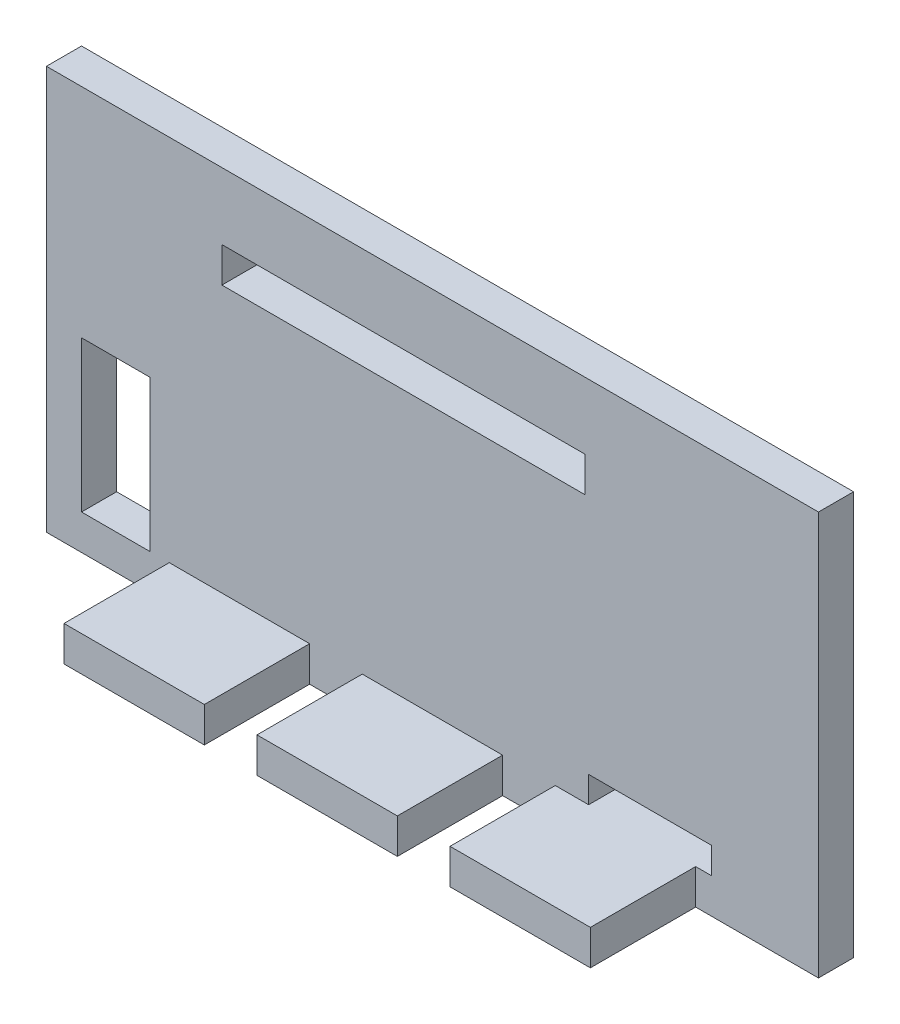
from build123d import *

# Parameters (mm, degrees)
SKETCH1_W           = 44
SKETCH1_H           = 23
BOSS_EXTRUDE1_DEPTH = 2
SKETCH2_W           = 3.9
SKETCH2_H           = 8.6
SKETCH2_W_2         = 7
SKETCH2_H_2         = 1.5
SKETCH2_W_3         = 20.7
SKETCH2_H_3         = 2
CUT_EXTRUDE1_DEPTH  = 2
SKETCH4_W           = 8
SKETCH4_H           = 2
BOSS_EXTRUDE2_DEPTH = 6


with BuildPart() as part:
    # Sketch1 → Boss-Extrude1 (new body)
    with BuildSketch(Plane.XY):
        Rectangle(SKETCH1_W, SKETCH1_H)
    extrude(amount=BOSS_EXTRUDE1_DEPTH)

    # Sketch2 → Cut-Extrude1 (cut)
    with BuildSketch(Plane.XY.offset(2)):
        with Locations((-18.05, -5.2)):
            Rectangle(SKETCH2_W, SKETCH2_H)
        with Locations((12.4, -8.75)):
            Rectangle(SKETCH2_W_2, SKETCH2_H_2)
        with Locations((-1.65, 6.7)):
            Rectangle(SKETCH2_W_3, SKETCH2_H_3)
    extrude(amount=-CUT_EXTRUDE1_DEPTH, mode=Mode.SUBTRACT)

    # Sketch4 → Boss-Extrude2 (add)
    with BuildSketch(Plane.XY.offset(2)):
        with Locations((-11, -10.5)):
            Rectangle(SKETCH4_W, SKETCH4_H)
        with Locations((0, -10.5)):
            Rectangle(SKETCH4_W, SKETCH4_H)
        with Locations((11, -10.5)):
            Rectangle(SKETCH4_W, SKETCH4_H)
    extrude(amount=BOSS_EXTRUDE2_DEPTH)


solid = part.part
